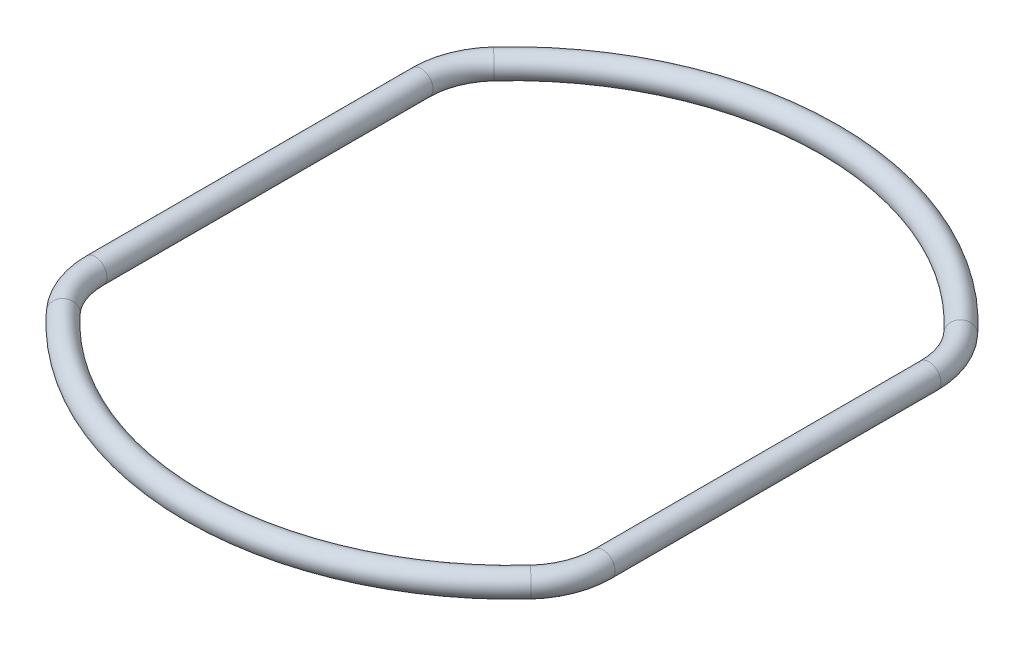
from build123d import *

# Parameters (mm, degrees)
SKIZZE2_R = 3.114282512


with BuildPart() as part:
    # Austragung1: sweep along a path in Skizze1
    with BuildLine(Plane(origin=(0, 0, 0), x_dir=(1, 0, 0), z_dir=(0, 1, 0))) as austragung1_path:
        ThreePointArc((0, -82.442660512), (-33.108990695, -75.502231804), (-60.643425983, -55.849504539))
        ThreePointArc((-60.643425983, -55.849504539), (-64.562830296, -49.572910331), (-65.931764421, -42.300814045))
        Line((-65.931764421, -42.300814045), (-65.931764421, 42.300814045))
        ThreePointArc((-65.931764421, 42.300814045), (-64.562830296, 49.572910331), (-60.643425983, 55.849504539))
        ThreePointArc((-60.643425983, 55.849504539), (-33.108990695, 75.502231804), (0, 82.442660512))
    # Skizze2 → Austragung1 (sweep)
    with BuildSketch(Plane(origin=(0, 0, 0), x_dir=(0, 0, -1), z_dir=(1, 0, 0))):
        with Locations((-82.442660512, 0)):
            Circle(SKIZZE2_R)
    sweep(path=austragung1_path.line)

    # Spiegeln1: part across plane


with BuildPart() as part_1:
    add(part.part)
    add(part.part.mirror(Plane(origin=(0, 0, 82.442660512), x_dir=(0, 0, 1), z_dir=(1, 0, 0))))


solid = part_1.part
